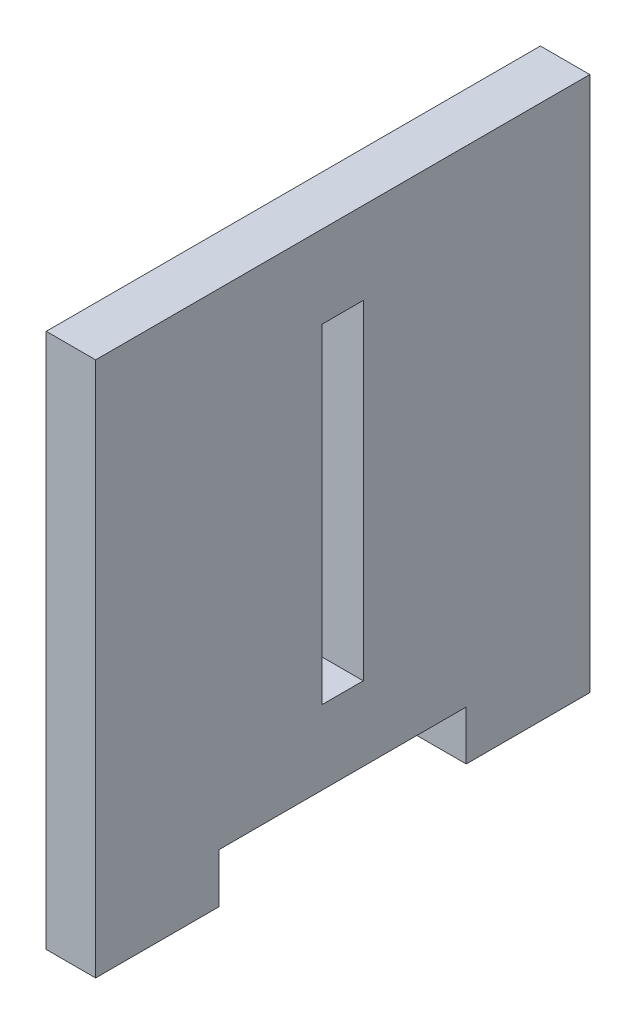
from build123d import *

# Parameters (mm, degrees)
SKETCH1_W           = 5
SKETCH1_H           = 40
BOSS_EXTRUDE1_DEPTH = 6


with BuildPart() as part:
    # Sketch1 → Boss-Extrude1 (new body)
    with BuildSketch(Plane(origin=(0, 0, 0), x_dir=(0, 0, -1), z_dir=(1, 0, 0))):
        Polygon((-15, 0), (0, 0), (0, 65), (-60, 65), (-60, 0), (-45, 0), (-45, 6), (-15, 6), align=None)
        with Locations((-30, 35)):
            Rectangle(SKETCH1_W, SKETCH1_H, mode=Mode.SUBTRACT)
    extrude(amount=BOSS_EXTRUDE1_DEPTH)


solid = part.part
